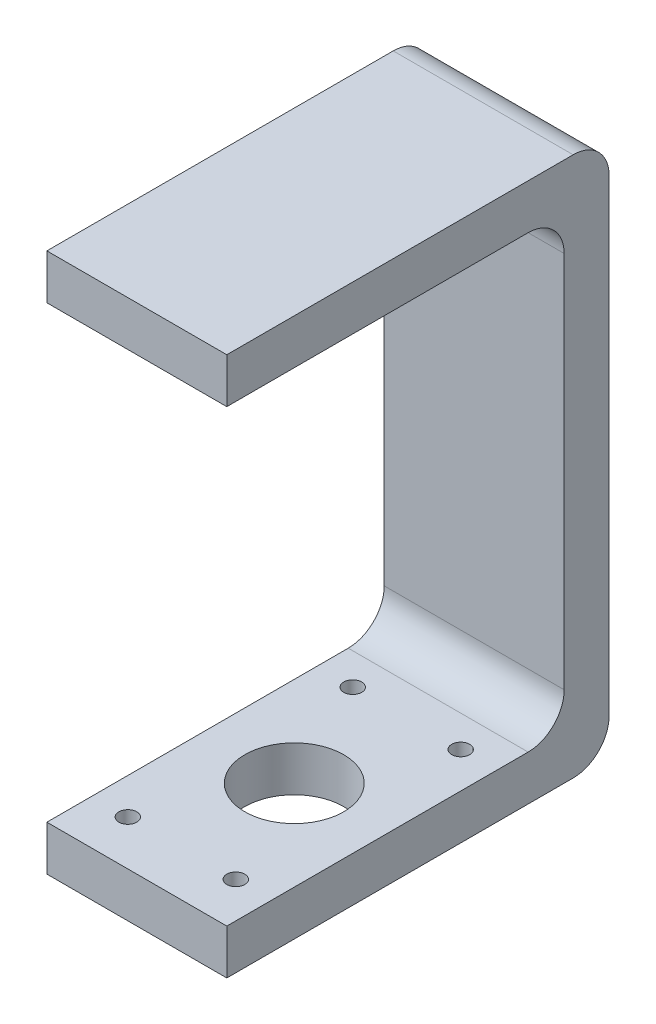
from build123d import *

# Parameters (mm, degrees)
EXTRUDE_1_DEPTH     = 40
CUT_EXTRUDE_1_REACH = 122
SKETCH_5_R          = 11
SKETCH_6_R          = 2
CUT_EXTRUDE_2_DEPTH = 20


with BuildPart() as part:
    # 草图1 → 凸台-拉伸1 (new body)
    with BuildSketch(Plane(origin=(0, 0, 0), x_dir=(0, 0, -1), z_dir=(1, 0, 0))):
        with BuildLine():
            Line((0, 0), (77, 0))
            ThreePointArc((77, 0), (82.656854249, 2.343145751), (85, 8))
            Line((85, 8), (85, 112))
            ThreePointArc((85, 112), (82.656854249, 117.656854249), (77, 120))
            Line((77, 120), (0, 120))
            Line((0, 120), (0, 110))
            Line((0, 110), (67, 110))
            ThreePointArc((67, 110), (72.656854249, 107.656854249), (75, 102))
            Line((75, 102), (75, 18))
            ThreePointArc((75, 18), (72.656854249, 12.343145751), (67, 10))
            Line((67, 10), (0, 10))
            Line((0, 10), (0, 0))
        make_face()
    extrude(amount=EXTRUDE_1_DEPTH)

    # 草图5 → 切除-拉伸1 (cut, up to next)
    with BuildSketch(Plane.XZ, mode=Mode.PRIVATE) as cut_extrude_1_sk1:
        with Locations((20, -35)):
            Circle(SKETCH_5_R)
    cut_extrude_1_tool1 = extrude(cut_extrude_1_sk1.sketch, amount=-CUT_EXTRUDE_1_REACH, mode=Mode.PRIVATE) & part.part
    add(cut_extrude_1_tool1.solids().sort_by_distance((20, 0, -35))[0], mode=Mode.SUBTRACT)

    # 草图6 → 切除-拉伸2 (cut)
    with BuildSketch(Plane.XZ):
        with Locations((8, -10)):
            Circle(SKETCH_6_R)
        with Locations((32, -10)):
            Circle(SKETCH_6_R)
        with Locations((8, -60)):
            Circle(SKETCH_6_R)
        with Locations((32, -60)):
            Circle(SKETCH_6_R)
    extrude(amount=-CUT_EXTRUDE_2_DEPTH, mode=Mode.SUBTRACT)


solid = part.part
